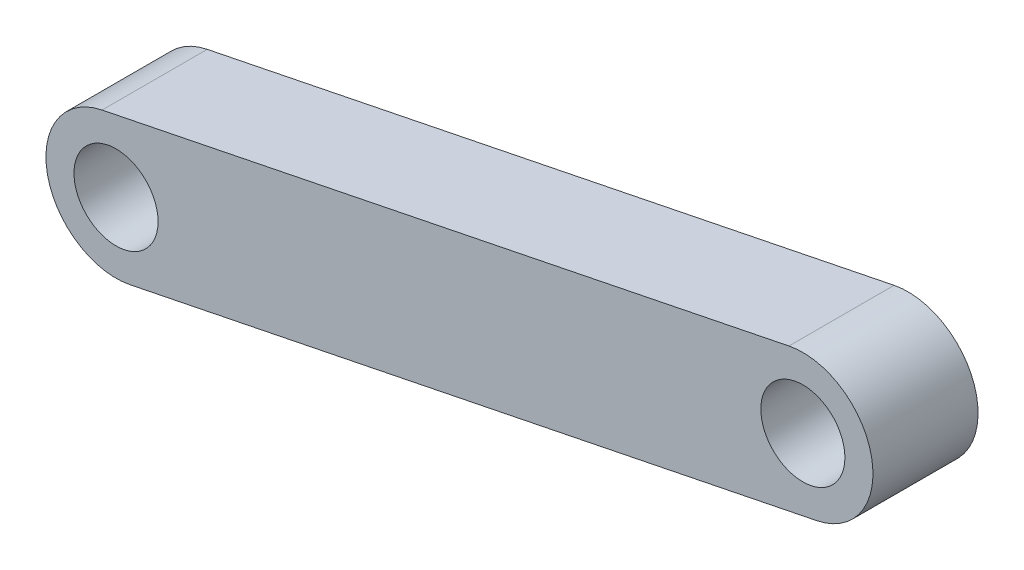
from build123d import *

# Parameters (mm, degrees)
SKETCH1_R           = 12
BOSS_EXTRUDE1_DEPTH = 30


with BuildPart() as part:
    # Sketch1 → Boss-Extrude1 (new body)
    with BuildSketch(Plane.XY):
        with BuildLine():
            Line((-3.969032643, 19.602213647), (192.05310383, 59.292540081))
            ThreePointArc((192.05310383, 59.292540081), (215.624350121, 43.659359077), (199.991169117, 20.088112786))
            Line((199.991169117, 20.088112786), (3.969032643, -19.602213647))
            ThreePointArc((3.969032643, -19.602213647), (-19.602213647, -3.969032643), (-3.969032643, 19.602213647))
        make_face()
        Circle(SKETCH1_R, mode=Mode.SUBTRACT)
        with Locations((196.022136473, 39.690326433)):
            Circle(SKETCH1_R, mode=Mode.SUBTRACT)
    extrude(amount=BOSS_EXTRUDE1_DEPTH)


solid = part.part
